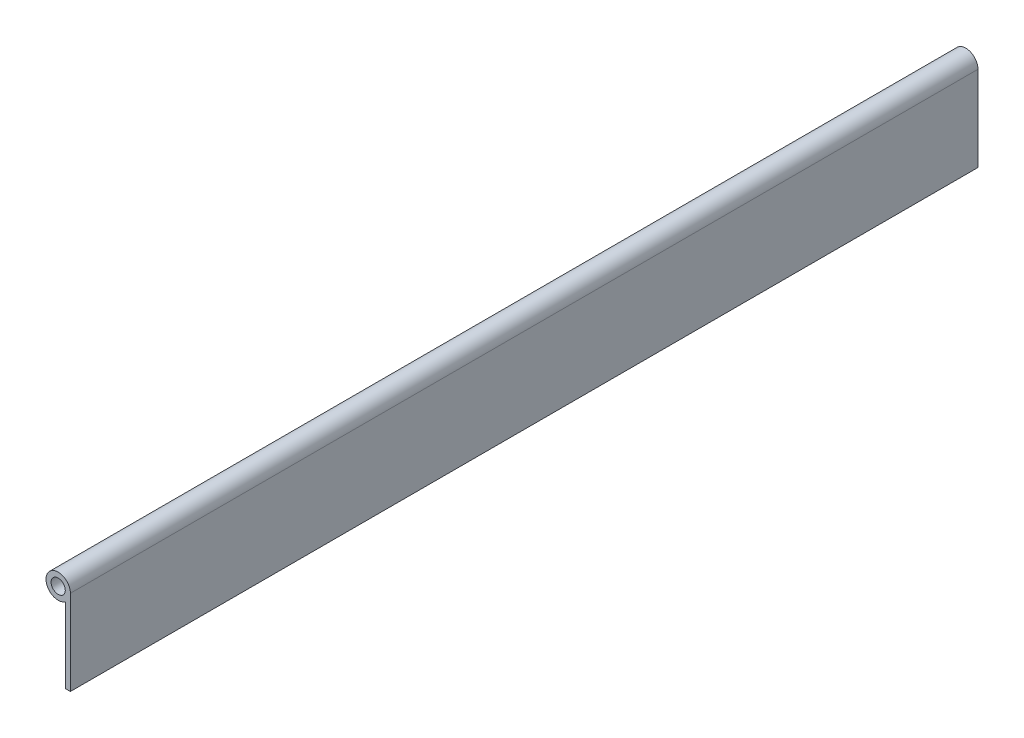
from build123d import *

# Parameters (mm, degrees)
SKETCH1_R           = 3.175
BOSS_EXTRUDE1_DEPTH = 406.4


with BuildPart() as part:
    # Sketch1 → Boss-Extrude1 (new body)
    with BuildSketch(Plane.XY):
        with BuildLine():
            Line((5.461, 0), (5.461, -38.1))
            Line((5.461, -38.1), (3.175, -38.1))
            Line((3.175, -38.1), (3.175, -4.443185344))
            ThreePointArc((3.175, -4.443185344), (-4.855985791, 2.498384078), (5.461, 0))
        make_face()
        Circle(SKETCH1_R, mode=Mode.SUBTRACT)
    extrude(amount=BOSS_EXTRUDE1_DEPTH)


solid = part.part
